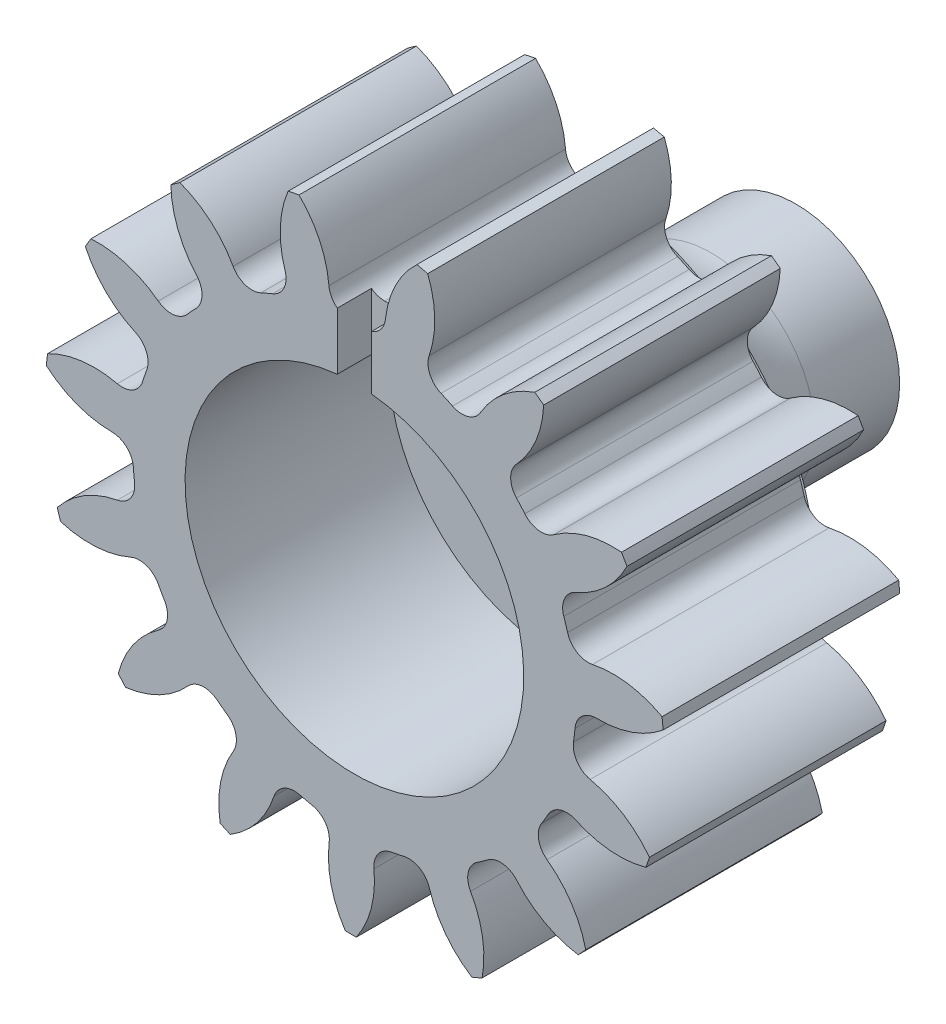
from build123d import *

# Parameters (mm, degrees)
SKETCH3_R          = 21.59
GEARBODY_DEPTH     = 11
TOOTHCUT_DEPTH     = 12
CIRPATTERN1_COUNT  = 15
SCALE1_SCALE_X     = 0.666666667
SCALE1_SCALE_Y     = 0.666666667
SCALE1_SCALE_Z     = 1
BOREDIA_R          = 7.874
BORE_DEPTH         = 12700
SKETCH5_R          = 2.65
CUT_EXTRUDE1_DEPTH = 3.745992
CUT_EXTRUDE4_DEPTH = 3.745992
CIRPATTERN2_COUNT  = 25
SKETCH7_W          = 1.5875
SKETCH7_H          = 7.384732118
CUT_EXTRUDE5_DEPTH = 1.5875


with BuildPart() as part:
    # Sketch3 → gearBody (new body)
    with BuildSketch(Plane.XY):
        Circle(SKETCH3_R)
    extrude(amount=GEARBODY_DEPTH)

    # Sketch2 → toothCut (cut, through all)
    with BuildSketch(Plane.XY):
        with BuildLine():
            ThreePointArc((23.557677296, 4.369859702), (20.903419497, 1.160165462), (16.90083789, 0.008400709))
            ThreePointArc((16.90083789, 0.008400709), (15.873647846, -0.373580438), (15.383737962, -1.353895329))
            ThreePointArc((15.383737962, -1.353895329), (15.338730146, -1.793260646), (15.281176485, -2.231159221))
            ThreePointArc((15.281176485, -2.231159221), (15.531746945, -3.298044138), (16.443125136, -3.906664523))
            ThreePointArc((16.443125136, -3.906664523), (20.072090929, -5.950638312), (21.914394526, -9.686028389))
            ThreePointArc((21.914394526, -9.686028389), (23.797464706, -2.782176655), (23.557677296, 4.369859702))
        make_face()
    toothcut = extrude(amount=TOOTHCUT_DEPTH, mode=Mode.SUBTRACT)

    # CirPattern1: toothCut ×15 about axis
    cirpattern1_axis = Axis((0, 0, 0), (0, 0, 1))
    for i in range(1, CIRPATTERN1_COUNT):
        add(toothcut.rotate(cirpattern1_axis, i * 360 / CIRPATTERN1_COUNT), mode=Mode.SUBTRACT)


with BuildPart() as part_1:
    # Scale1: scaled about (0, 0, 5.5)
    add(part.part.scale((SCALE1_SCALE_X, SCALE1_SCALE_Y, SCALE1_SCALE_Z), about=(0, 0, 5.5)))

    # boreDia → bore (cut, symmetric)
    with BuildSketch(Plane.XY):
        Circle(BOREDIA_R)
    extrude(amount=BORE_DEPTH, both=True, mode=Mode.SUBTRACT)

    # Sketch4 → Revolve1 (revolve)
    with BuildSketch(Plane(origin=(0, 0, 0), x_dir=(0, 0, -1), z_dir=(1, 0, 0))):
        with BuildLine():
            Line((9.525, 0), (-1.524, 0))
            Line((-1.524, 0), (-1.524, 7.874))
            Line((-1.524, 7.874), (0, 7.874))
            Line((0, 7.874), (0, 10.414))
            ThreePointArc((0, 10.414), (1.636687307, 6.462687307), (5.588, 4.826))
            Line((5.588, 4.826), (9.525, 4.826))
            Line((9.525, 4.826), (9.525, 0))
        make_face()
    revolve(axis=Axis((0, 0, 0), (0, 0, -1)))

    # Sketch5 → Cut-Extrude1 (cut)
    with BuildSketch(Plane(origin=(0, 0, -9.525), x_dir=(-1, 0, 0), z_dir=(0, 0, -1))):
        Circle(SKETCH5_R)
    extrude(amount=-CUT_EXTRUDE1_DEPTH, mode=Mode.SUBTRACT)

    # Sketch6 → Cut-Extrude4 (cut)
    with BuildSketch(Plane(origin=(0, 0, -9.525), x_dir=(-1, 0, 0), z_dir=(0, 0, -1))):
        with BuildLine():
            Line((0.06, 3.049409779), (0.23, 2.64))
            ThreePointArc((0.23, 2.64), (0, 2.65), (-0.23, 2.64))
            Line((-0.23, 2.64), (-0.06, 3.049409779))
            ThreePointArc((-0.06, 3.049409779), (0, 3.05), (0.06, 3.049409779))
        make_face()
    cut_extrude4 = extrude(amount=-CUT_EXTRUDE4_DEPTH, mode=Mode.SUBTRACT)

    # CirPattern2: Cut-Extrude4 ×25 about axis
    cirpattern2_axis = Axis((0, 0, 0), (0, 0, 1))
    for i in range(1, CIRPATTERN2_COUNT):
        add(cut_extrude4.rotate(cirpattern2_axis, i * 360 / CIRPATTERN2_COUNT), mode=Mode.SUBTRACT)

    # Sketch7 → Cut-Extrude5 (cut)
    with BuildSketch(Plane.XY.offset(11)):
        with Locations((0, 9.486214323)):
            Rectangle(SKETCH7_W, SKETCH7_H)
    extrude(amount=-CUT_EXTRUDE5_DEPTH, mode=Mode.SUBTRACT)


solid = part_1.part
